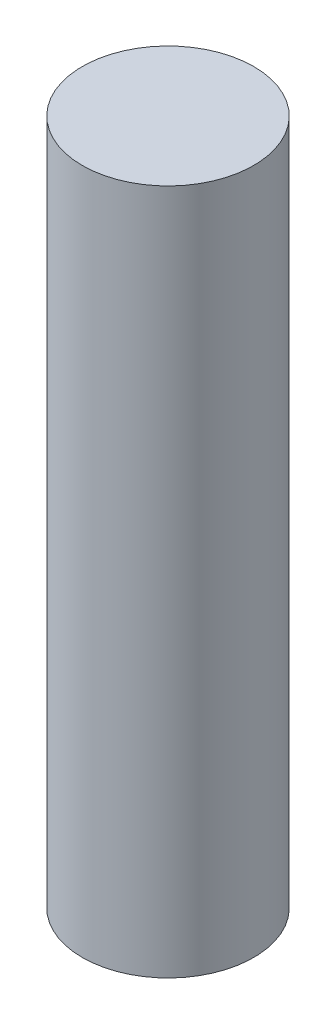
from build123d import *

# Parameters (mm, degrees)
CROQUIS1_R              = 7.5
SALIENTE_EXTRUIR1_DEPTH = 60


with BuildPart() as part:
    # Croquis1 → Saliente-Extruir1 (new body)
    with BuildSketch(Plane(origin=(0, 0, 0), x_dir=(1, 0, 0), z_dir=(0, 1, 0))):
        Circle(CROQUIS1_R)
    extrude(amount=SALIENTE_EXTRUIR1_DEPTH)


solid = part.part
